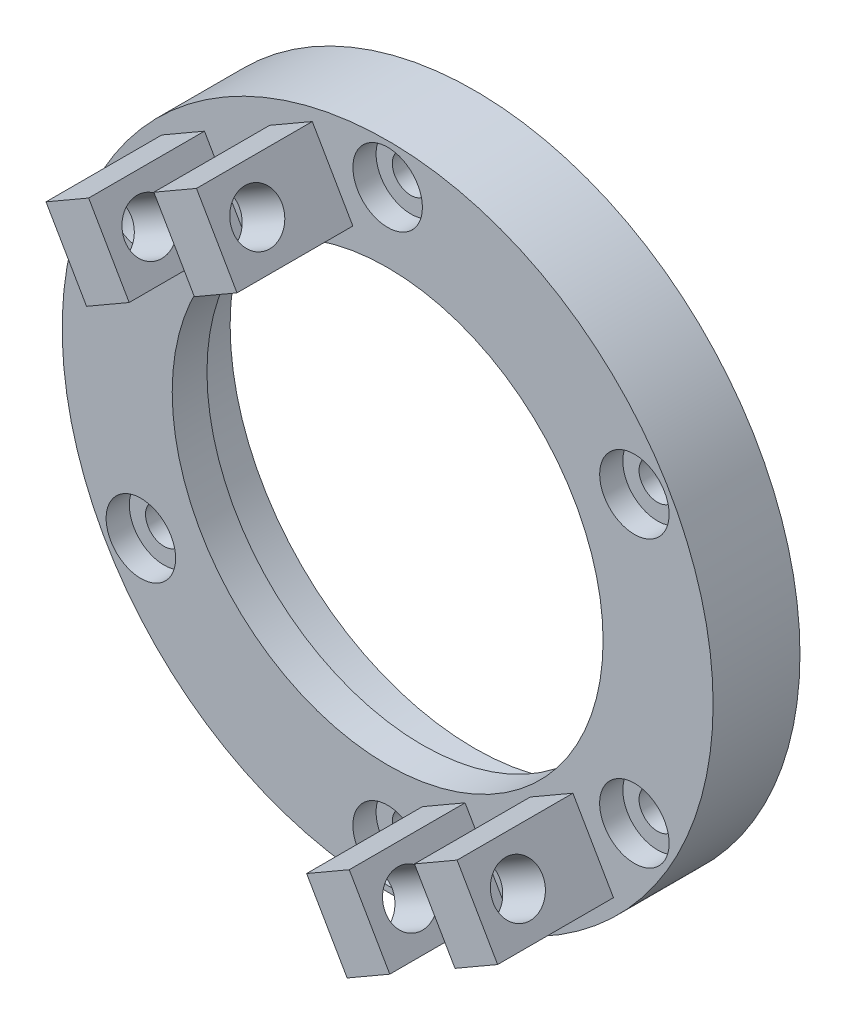
from build123d import *

# Parameters (mm, degrees)
SKETCH1_R            = 28.1
SKETCH1_R_2          = 21.1
BOSS_EXTRUDE1_DEPTH  = 4.5
SKETCH2_R            = 28.1
SKETCH2_R_2          = 18.6
BOSS_EXTRUDE2_DEPTH  = 3
M3_CLEARANCE_HOLE1_D = 3.2
SKETCH6_R            = 3
CUT_EXTRUDE1_DEPTH   = 2
BOSS_EXTRUDE3_DEPTH  = 10
SKETCH8_R            = 2.125
CUT_EXTRUDE2_DEPTH   = 15
SKETCH9_W            = 6.5
SKETCH9_H            = 10
CUT_EXTRUDE3_DEPTH   = 7
CIRPATTERN1_COUNT    = 6
CIRPATTERN2_COUNT    = 2


with BuildPart() as part:
    # Sketch1 → Boss-Extrude1 (new body)
    with BuildSketch(Plane.XY):
        Circle(SKETCH1_R)
        Circle(SKETCH1_R_2, mode=Mode.SUBTRACT)
    extrude(amount=BOSS_EXTRUDE1_DEPTH)

    # Sketch2 → Boss-Extrude2 (add)
    with BuildSketch(Plane.XY.offset(4.5)):
        Circle(SKETCH2_R)
        Circle(SKETCH2_R_2, mode=Mode.SUBTRACT)
    extrude(amount=BOSS_EXTRUDE2_DEPTH)

    # M3 Clearance Hole1 (through all)
    with Locations(Plane(origin=(0, 0, 0), x_dir=(-1, 0, 0), z_dir=(0, 0, -1))):
        with Locations((0, 24.6)):
            m3_clearance_hole1 = Hole(M3_CLEARANCE_HOLE1_D / 2)

    # Sketch6 → Cut-Extrude1 (cut)
    with BuildSketch(Plane.XY.offset(7.5)):
        with Locations((0, 24.6)):
            Circle(SKETCH6_R)
    cut_extrude1 = extrude(amount=-CUT_EXTRUDE1_DEPTH, mode=Mode.SUBTRACT)

    # Sketch7 → Boss-Extrude3 (add)
    with BuildSketch(Plane.XY.offset(7.5)):
        Polygon((-6.504809472, 26.266660498), (-19.495190528, 18.766660498), (-15.995190528, 12.704482672), (-3.004809472, 20.204482672), align=None)
    boss_extrude3 = extrude(amount=BOSS_EXTRUDE3_DEPTH)

    # Sketch8 → Cut-Extrude2 (cut)
    with BuildSketch(Plane(origin=(-6.495190528, -3.75, 0), x_dir=(0, 0, 1), z_dir=(-0.866025404, -0.5, 0))):
        with Locations((14, 22.5)):
            Circle(SKETCH8_R)
    cut_extrude2 = extrude(amount=-CUT_EXTRUDE2_DEPTH, mode=Mode.SUBTRACT)

    # Sketch9 → Cut-Extrude3 (cut)
    with BuildSketch(Plane(origin=(-13, 22.516660498, 0), x_dir=(0.866025404, 0.5, 0), z_dir=(-0.5, 0.866025404, 0))):
        with Locations((0, -12.5)):
            Rectangle(SKETCH9_W, SKETCH9_H)
    cut_extrude3 = extrude(amount=-CUT_EXTRUDE3_DEPTH, mode=Mode.SUBTRACT)

    # CirPattern1: M3 Clearance Hole1, Cut-Extrude1 ×6 about axis
    cirpattern1_axis = Axis((0, 0, 0), (0, 0, 1))
    for i in range(1, CIRPATTERN1_COUNT):
        add(m3_clearance_hole1.rotate(cirpattern1_axis, i * 360 / CIRPATTERN1_COUNT), mode=Mode.SUBTRACT)
        add(cut_extrude1.rotate(cirpattern1_axis, i * 360 / CIRPATTERN1_COUNT), mode=Mode.SUBTRACT)

    # CirPattern2: Boss-Extrude3, Cut-Extrude2, Cut-Extrude3 ×2 about axis
    cirpattern2_axis = Axis((0, 0, 0), (0, 0, 1))
    for i in range(1, CIRPATTERN2_COUNT):
        add(boss_extrude3.rotate(cirpattern2_axis, i * 360 / CIRPATTERN2_COUNT))
        add(cut_extrude2.rotate(cirpattern2_axis, i * 360 / CIRPATTERN2_COUNT), mode=Mode.SUBTRACT)
        add(cut_extrude3.rotate(cirpattern2_axis, i * 360 / CIRPATTERN2_COUNT), mode=Mode.SUBTRACT)


solid = part.part
